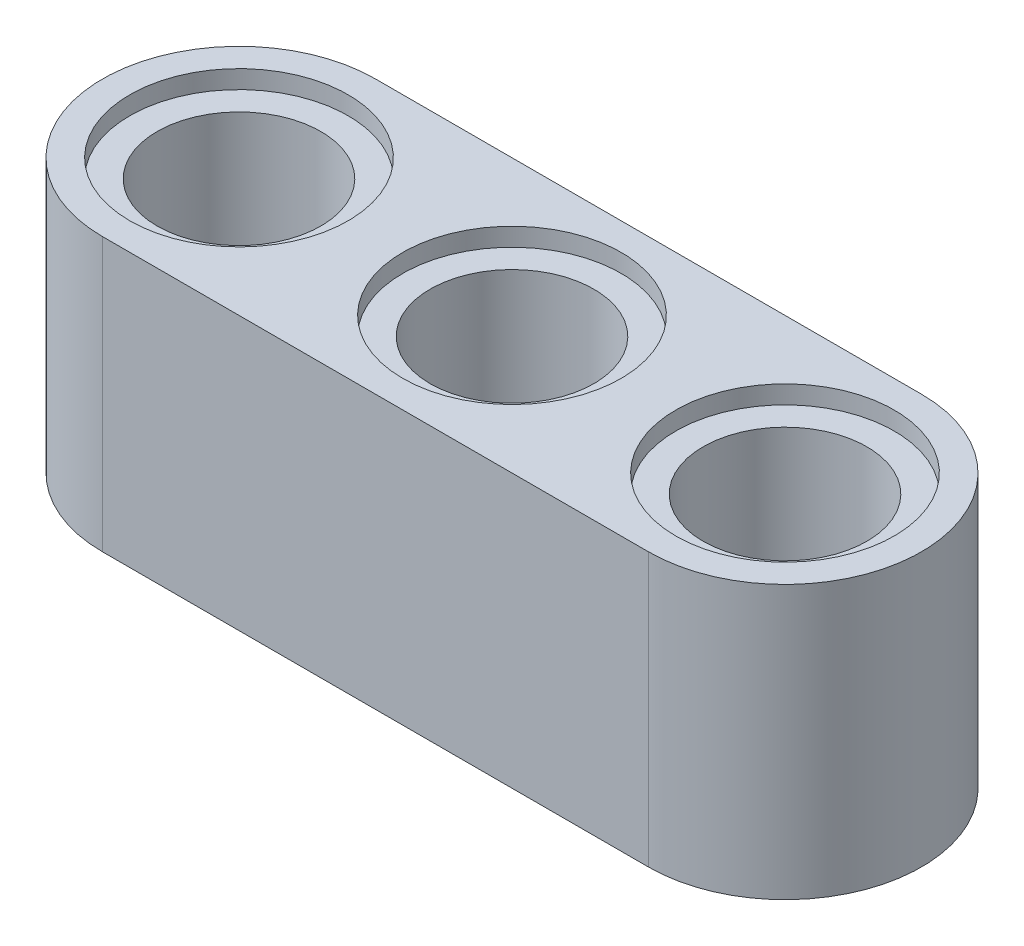
from build123d import *

# Parameters (mm, degrees)
SKETCH1_R           = 1.5
BOSS_EXTRUDE3_DEPTH = 2.5
SKETCH1_5_R         = 2
SKETCH1_5_R_2       = 1.5
CUT_EXTRUDE1_DEPTH  = 0.333333333


with BuildPart() as part:
    # Sketch1 → Boss-Extrude3 (new body)
    with BuildSketch(Plane(origin=(0, 0, 0), x_dir=(1, 0, 0), z_dir=(0, 1, 0))):
        with BuildLine():
            Line((12.5, 5), (2.5, 5))
            ThreePointArc((2.5, 5), (0, 2.5), (2.5, 0))
            Line((2.5, 0), (12.5, 0))
            ThreePointArc((12.5, 0), (15, 2.5), (12.5, 5))
        make_face()
        with Locations((7.5, 2.5)):
            Circle(SKETCH1_R, mode=Mode.SUBTRACT)
        with Locations((2.5, 2.5)):
            Circle(SKETCH1_R, mode=Mode.SUBTRACT)
        with Locations((12.5, 2.5)):
            Circle(SKETCH1_R, mode=Mode.SUBTRACT)
    boss_extrude3 = extrude(amount=BOSS_EXTRUDE3_DEPTH)

    # Sketch1_5 → Cut-Extrude1 (cut)
    # profile 1 of 3: a face of its own
    with BuildSketch(Plane(origin=(0, 0, 0), x_dir=(1, 0, 0), z_dir=(0, 1, 0))):
        with Locations((2.5, 2.5)):
            Circle(SKETCH1_5_R)
        with Locations((2.5, 2.5)):
            Circle(SKETCH1_5_R_2, mode=Mode.SUBTRACT)
    # profile 2 of 3: a face of its own
    with BuildSketch(Plane(origin=(0, 0, 0), x_dir=(1, 0, 0), z_dir=(0, 1, 0))):
        with Locations((7.5, 2.5)):
            Circle(SKETCH1_5_R)
        with Locations((7.5, 2.5)):
            Circle(SKETCH1_5_R_2, mode=Mode.SUBTRACT)
    # profile 3 of 3: a face of its own
    with BuildSketch(Plane(origin=(0, 0, 0), x_dir=(1, 0, 0), z_dir=(0, 1, 0))):
        with Locations((12.5, 2.5)):
            Circle(SKETCH1_5_R)
        with Locations((12.5, 2.5)):
            Circle(SKETCH1_5_R_2, mode=Mode.SUBTRACT)
    cut_extrude1 = extrude(amount=CUT_EXTRUDE1_DEPTH, mode=Mode.SUBTRACT)

    # Mirror2: Boss-Extrude3, Cut-Extrude1 across plane
    add(boss_extrude3.mirror(Plane.ZX.offset(2.5)))
    add(cut_extrude1.mirror(Plane.ZX.offset(2.5)), mode=Mode.SUBTRACT)


solid = part.part
